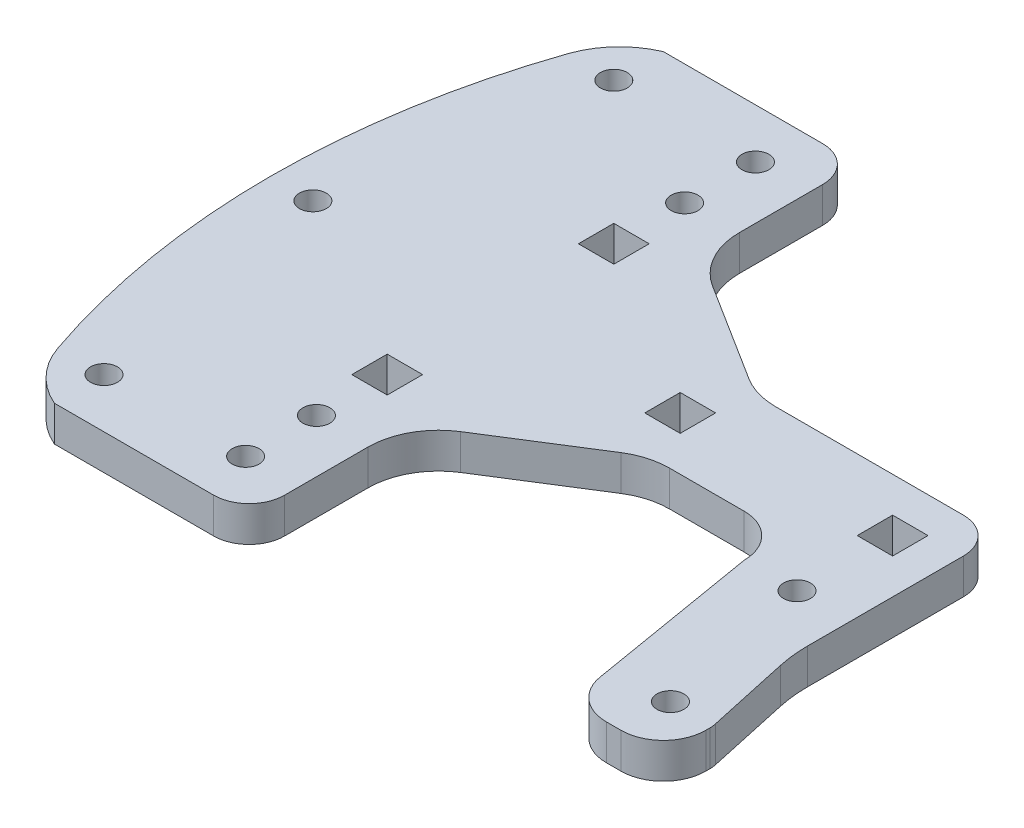
from build123d import *

# Parameters (mm, degrees)
SKETCH1_R           = 2.413
SKETCH1_W           = 6.35
SKETCH1_H           = 6.35
BOSS_EXTRUDE1_DEPTH = 6.35


with BuildPart() as part:
    # Sketch1 → Boss-Extrude1 (new body)
    with BuildSketch(Plane(origin=(0, 0, 0), x_dir=(1, 0, 0), z_dir=(0, 1, 0))):
        with BuildLine():
            Line((-4.276232573, 19.216684391), (-37.939187052, 19.216684391))
            ThreePointArc((-37.939187052, 19.216684391), (-41.464378908, 19.715740887), (-44.712520386, 21.17368874))
            Line((-44.712520386, 21.17368874), (-62.328552859, 32.280391547))
            ThreePointArc((-62.328552859, 32.280391547), (-66.67527648, 36.888704376), (-68.255219526, 43.023387198))
            Line((-68.255219526, 43.023387198), (-68.255219526, 57.951684391))
            ThreePointArc((-68.255219526, 57.951684391), (-70.115091465, 62.441812452), (-74.605219526, 64.301684391))
            Line((-74.605219526, 64.301684391), (-103.180219526, 64.301684391))
            ThreePointArc((-103.180219526, 64.301684391), (-108.250679153, 60.73228976), (-111.435219526, 55.411684391))
            ThreePointArc((-111.435219526, 55.411684391), (-119.055219526, 9.691684391), (-111.435219526, -36.028315609))
            ThreePointArc((-111.435219526, -36.028315609), (-108.250679153, -41.348920977), (-103.180219526, -44.918315609))
            Line((-103.180219526, -44.918315609), (-74.605219526, -44.918315609))
            ThreePointArc((-74.605219526, -44.918315609), (-70.115091465, -43.058443669), (-68.255219526, -38.568315609))
            Line((-68.255219526, -38.568315609), (-68.255219526, -23.640018416))
            ThreePointArc((-68.255219526, -23.640018416), (-66.67527648, -17.505335593), (-62.328552859, -12.897022765))
            Line((-62.328552859, -12.897022765), (-44.712520386, -1.790319958))
            ThreePointArc((-44.712520386, -1.790319958), (-41.464378908, -0.332372105), (-37.939187052, 0.166684391))
            Line((-37.939187052, 0.166684391), (-27.387614836, 0.166684391))
            Line((-27.387614836, 0.166684391), (-24.553673229, 0.166684391))
            ThreePointArc((-24.553673229, 0.166684391), (-19.165519557, -2.065161936), (-16.933673229, -7.453315609))
            Line((-16.933673229, -7.453315609), (-11.696120928, -38.563381903))
            ThreePointArc((-11.696120928, -38.563381903), (-9.102466616, -43.116571583), (-4.181867321, -44.918315609))
            Line((-4.181867321, -44.918315609), (-1.580219526, -44.918315609))
            ThreePointArc((-1.580219526, -44.918315609), (3.807934147, -42.686469281), (6.039780474, -37.298315609))
            Line((6.039780474, -37.298315609), (6.039780474, -36.576031258))
            ThreePointArc((6.039780474, -36.576031258), (6.010508622, -36.031471642), (5.923030406, -35.493187723))
            Line((5.923030406, -35.493187723), (2.657517771, -20.525600214))
            ThreePointArc((2.657517771, -20.525600214), (2.220126687, -17.834180618), (2.073767427, -15.111382542))
            Line((2.073767427, -15.111382542), (2.073767427, 5.246684391))
            Line((2.073767427, 5.246684391), (2.073767427, 12.866684391))
            ThreePointArc((2.073767427, 12.866684391), (0.213895488, 17.356812452), (-4.276232573, 19.216684391))
        make_face()
        with Locations((-103.180219526, -36.028315609)):
            Circle(SKETCH1_R, mode=Mode.SUBTRACT)
        with Locations((-77.780219526, -36.028315609)):
            Circle(SKETCH1_R, mode=Mode.SUBTRACT)
        with Locations((-77.780219526, -23.328315609)):
            Circle(SKETCH1_R, mode=Mode.SUBTRACT)
        with Locations((-77.780219526, -10.628315609)):
            Rectangle(SKETCH1_W, SKETCH1_H, mode=Mode.SUBTRACT)
        with Locations((-1.580219526, -36.028315609)):
            Circle(SKETCH1_R, mode=Mode.SUBTRACT)
        with Locations((-7.451232573, -7.453315609)):
            Circle(SKETCH1_R, mode=Mode.SUBTRACT)
        with Locations((-111.435219526, 9.691684391)):
            Circle(SKETCH1_R, mode=Mode.SUBTRACT)
        with Locations((-77.780219526, 30.011684391)):
            Rectangle(SKETCH1_W, SKETCH1_H, mode=Mode.SUBTRACT)
        with Locations((-103.180219526, 55.411684391)):
            Circle(SKETCH1_R, mode=Mode.SUBTRACT)
        with Locations((-77.780219526, 42.711684391)):
            Circle(SKETCH1_R, mode=Mode.SUBTRACT)
        with Locations((-77.780219526, 55.411684391)):
            Circle(SKETCH1_R, mode=Mode.SUBTRACT)
        with Locations((-45.551232573, 9.691684391)):
            Rectangle(SKETCH1_W, SKETCH1_H, mode=Mode.SUBTRACT)
        with Locations((-7.451232573, 9.691684391)):
            Rectangle(SKETCH1_W, SKETCH1_H, mode=Mode.SUBTRACT)
    extrude(amount=BOSS_EXTRUDE1_DEPTH)


solid = part.part
